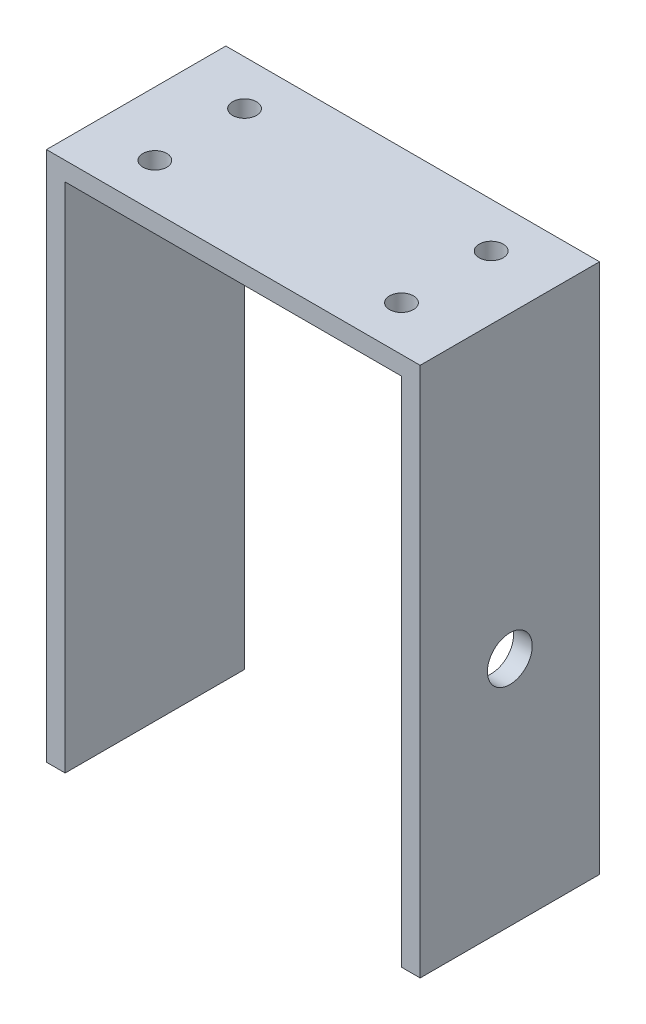
from build123d import *

# Parameters (mm, degrees)
SKETCH_1_W                      = 50
SKETCH_1_H                      = 100
SKETCH_1_W_2                    = 45
SKETCH_1_H_2                    = 95
EXTRUDE_1_DEPTH                 = 24
SKETCH_3_R                      = 1.6
CUT_EXTRUDE_2_DEPTH             = 1
CUT_EXTRUDE_2_DEPTH_BACK        = 101
CUT_EXTRUDE_3_REACH             = 52
SKETCH_4_R                      = 3
SKETCH_4_R_2                    = 4
CUT_EXTRUDE_3_DIRECTION_2_DEPTH = 1
SKETCH_5_W                      = 50
SKETCH_5_H                      = 24
CUT_EXTRUDE_4_DEPTH             = 29


with BuildPart() as part:
    # ｽｹｯﾁ1 → ﾎﾞｽ - 押し出し1 (new body)
    with BuildSketch(Plane.XY):
        Rectangle(SKETCH_1_W, SKETCH_1_H)
        Rectangle(SKETCH_1_W_2, SKETCH_1_H_2, mode=Mode.SUBTRACT)
    extrude(amount=EXTRUDE_1_DEPTH)

    # ｽｹｯﾁ3 → ｶｯﾄ - 押し出し2 (cut, two sides)
    with BuildSketch(Plane(origin=(0, 50, 0), x_dir=(1, 0, 0), z_dir=(0, 1, 0))) as cut_extrude_2_sk:
        with Locations((-16.5, -6)):
            Circle(SKETCH_3_R)
        with Locations((16.5, -6)):
            Circle(SKETCH_3_R)
        with Locations((16.5, -18)):
            Circle(SKETCH_3_R)
        with Locations((-16.5, -18)):
            Circle(SKETCH_3_R)
    extrude(amount=CUT_EXTRUDE_2_DEPTH, mode=Mode.SUBTRACT)
    extrude(cut_extrude_2_sk.sketch, amount=-CUT_EXTRUDE_2_DEPTH_BACK, mode=Mode.SUBTRACT)

    # ｽｹｯﾁ4 → ｶｯﾄ - 押し出し3 (cut, up to next)
    with BuildSketch(Plane(origin=(25, 0, 0), x_dir=(0, 0, -1), z_dir=(1, 0, 0)), mode=Mode.PRIVATE) as cut_extrude_3_sk1:
        with Locations((-12, 10)):
            Circle(SKETCH_4_R)
    cut_extrude_3_tool1 = extrude(cut_extrude_3_sk1.sketch, amount=-CUT_EXTRUDE_3_REACH, mode=Mode.PRIVATE) & part.part
    add(cut_extrude_3_tool1.solids().sort_by_distance((25, 10, 12))[0], mode=Mode.SUBTRACT)
    # ｽｹｯﾁ4 → ｶｯﾄ - 押し出し3 (cut, up to next)
    with BuildSketch(Plane(origin=(25, 0, 0), x_dir=(0, 0, -1), z_dir=(1, 0, 0)), mode=Mode.PRIVATE) as cut_extrude_3_sk2:
        with Locations((-12, -30)):
            Circle(SKETCH_4_R_2)
    cut_extrude_3_tool2 = extrude(cut_extrude_3_sk2.sketch, amount=-CUT_EXTRUDE_3_REACH, mode=Mode.PRIVATE) & part.part
    add(cut_extrude_3_tool2.solids().sort_by_distance((25, -30, 12))[0], mode=Mode.SUBTRACT)

    # ｽｹｯﾁ4 → ｶｯﾄ - 押し出し3 direction 2 (cut)
    with BuildSketch(Plane(origin=(25, 0, 0), x_dir=(0, 0, -1), z_dir=(1, 0, 0))):
        with Locations((-12, 10)):
            Circle(SKETCH_4_R)
        with Locations((-12, -30)):
            Circle(SKETCH_4_R_2)
    extrude(amount=CUT_EXTRUDE_3_DIRECTION_2_DEPTH, mode=Mode.SUBTRACT)

    # ｽｹｯﾁ5 → ｶｯﾄ - 押し出し4 (cut)
    with BuildSketch(Plane.XZ.offset(50)):
        with Locations((0, 12)):
            Rectangle(SKETCH_5_W, SKETCH_5_H)
    extrude(amount=-CUT_EXTRUDE_4_DEPTH, mode=Mode.SUBTRACT)


solid = part.part
